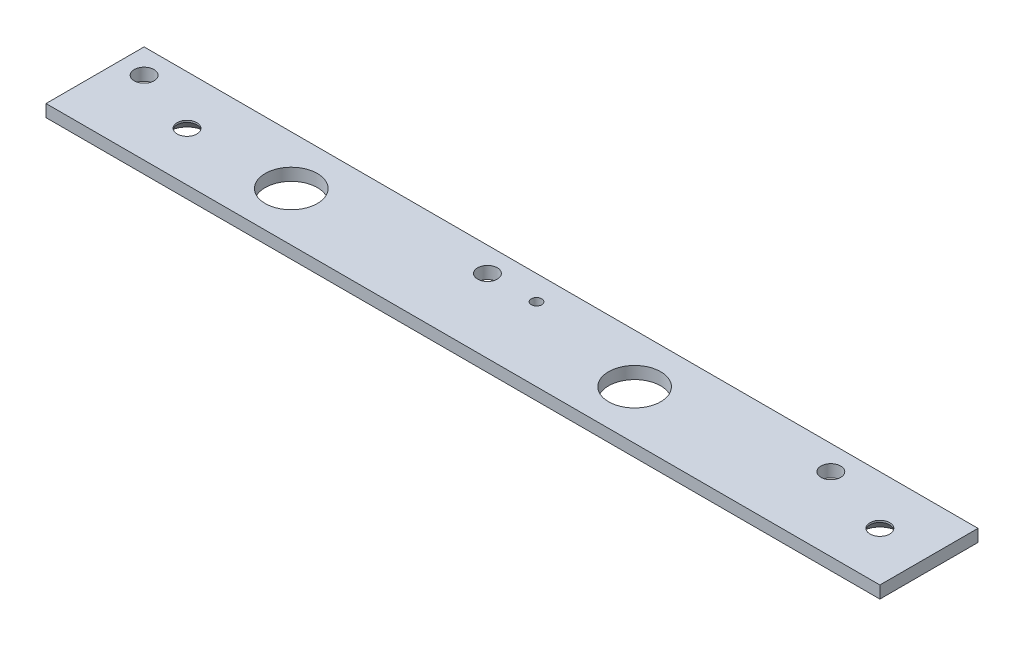
from build123d import *

# Parameters (mm, degrees)
SKETCH1_W                                    = 25.4
SKETCH1_H                                    = 3.175
BOSS_EXTRUDE1_DEPTH                          = 107.95
F_10_CLEARANCE_HOLE1_D                       = 5.1054
F_1_2_CLEARANCE_HOLE1_D                      = 13.49248
F_6_32_TAPPED_HOLE1_D                        = 2.7051
CSK_FOR_10_FLAT_HEAD_MACHINE_SCREW1_AT_COUNT = 2
CSK_FOR_10_FLAT_HEAD_MACHINE_SCREW1_AT_PITCH = 50.8
CSK_FOR_10_FLAT_HEAD_MACHINE_SCREW1_2_COUNT  = 2
CSK_FOR_10_FLAT_HEAD_MACHINE_SCREW1_2_PITCH  = 186.441720536
CSK_FOR_10_FLAT_HEAD_MACHINE_SCREW1_3_COUNT  = 2
CSK_FOR_10_FLAT_HEAD_MACHINE_SCREW1_3_PITCH  = 179.3875
CSK_FOR_10_FLAT_HEAD_MACHINE_SCREW1_4_COUNT  = 2
CSK_FOR_10_FLAT_HEAD_MACHINE_SCREW1_4_PITCH  = 331.7875
CSK_FOR_10_FLAT_HEAD_MACHINE_SCREW1_5_COUNT  = 2
CSK_FOR_10_FLAT_HEAD_MACHINE_SCREW1_5_PITCH  = 152.4
CSK_FOR_10_FLAT_HEAD_MACHINE_SCREW1_6_COUNT  = 2
CSK_FOR_10_FLAT_HEAD_MACHINE_SCREW1_6_PITCH  = 160.643705137
CSK_FOR_10_FLAT_HEAD_MACHINE_SCREW1_7_COUNT  = 2
CSK_FOR_10_FLAT_HEAD_MACHINE_SCREW1_7_PITCH  = 335.653966394


with BuildPart() as part:
    # Sketch1 → Boss-Extrude1 (new body, symmetric)
    with BuildSketch(Plane(origin=(0, 0, 0), x_dir=(0, 0, -1), z_dir=(1, 0, 0))):
        Rectangle(SKETCH1_W, SKETCH1_H)
    extrude(amount=BOSS_EXTRUDE1_DEPTH, both=True)

    # #10 Clearance Hole1 (through all)
    with Locations(Plane(origin=(0, 1.5875, 0), x_dir=(1, 0, 0), z_dir=(0, 1, 0))):
        with Locations((-101.6, 6.35), (-12.7, 6.35), (76.2, 6.35)):
            Hole(F_10_CLEARANCE_HOLE1_D / 2)

    # 1/2 Clearance Hole1 (through all)
    with Locations(Plane(origin=(0, 1.5875, 0), x_dir=(1, 0, 0), z_dir=(0, 1, 0))):
        with Locations((-57.15, 0), (31.75, 0)):
            Hole(F_1_2_CLEARANCE_HOLE1_D / 2)

    # #6-32 Tapped Hole1 (through all)
    with Locations(Plane(origin=(0, 1.5875, 0), x_dir=(1, 0, 0), z_dir=(0, 1, 0))):
        with Locations((0, 6.35)):
            Hole(F_6_32_TAPPED_HOLE1_D / 2)

    # Sketch9 → CSK for #10 Flat Head Machine Screw1 (revolve, cut)
    with BuildSketch(Plane(origin=(95.25, -1.5875, 50.8), x_dir=(0, 0, -1), z_dir=(1, 0, 0))):
        Polygon((0, 0), (0, 3.175), (2.5527, 3.175), (2.5527, 2.688180894), (4.8895, 0), align=None)
    csk_for_10_flat_head_machine_screw1 = revolve(axis=Axis((95.25, -7.9375, 50.8), (0, 1, 0)), mode=Mode.SUBTRACT)

    # CSK for #10 Flat Head Machine Screw1 at: CSK for #10 Flat Head Machine Screw1 ×2
    with Locations(*[(0, 0, -i * CSK_FOR_10_FLAT_HEAD_MACHINE_SCREW1_AT_PITCH) for i in range(1, CSK_FOR_10_FLAT_HEAD_MACHINE_SCREW1_AT_COUNT)]):
        add(csk_for_10_flat_head_machine_screw1, mode=Mode.SUBTRACT)

    # CSK for _10 Flat Head Machine Screw1 2: CSK for #10 Flat Head Machine Screw1 ×2
    with Locations(*[Vector(-0.962163938, 0, -0.272471204) * (i * CSK_FOR_10_FLAT_HEAD_MACHINE_SCREW1_2_PITCH) for i in range(1, CSK_FOR_10_FLAT_HEAD_MACHINE_SCREW1_2_COUNT)]):
        add(csk_for_10_flat_head_machine_screw1, mode=Mode.SUBTRACT)

    # CSK for _10 Flat Head Machine Screw1 3: CSK for #10 Flat Head Machine Screw1 ×2
    with Locations(*[(-i * CSK_FOR_10_FLAT_HEAD_MACHINE_SCREW1_3_PITCH, 0, 0) for i in range(1, CSK_FOR_10_FLAT_HEAD_MACHINE_SCREW1_3_COUNT)]):
        add(csk_for_10_flat_head_machine_screw1, mode=Mode.SUBTRACT)

    # CSK for _10 Flat Head Machine Screw1 4: CSK for #10 Flat Head Machine Screw1 ×2
    with Locations(*[(i * CSK_FOR_10_FLAT_HEAD_MACHINE_SCREW1_4_PITCH, 0, 0) for i in range(1, CSK_FOR_10_FLAT_HEAD_MACHINE_SCREW1_4_COUNT)]):
        add(csk_for_10_flat_head_machine_screw1, mode=Mode.SUBTRACT)

    # CSK for _10 Flat Head Machine Screw1 5: CSK for #10 Flat Head Machine Screw1 ×2
    with Locations(*[(i * CSK_FOR_10_FLAT_HEAD_MACHINE_SCREW1_5_PITCH, 0, 0) for i in range(1, CSK_FOR_10_FLAT_HEAD_MACHINE_SCREW1_5_COUNT)]):
        add(csk_for_10_flat_head_machine_screw1, mode=Mode.SUBTRACT)

    # CSK for _10 Flat Head Machine Screw1 6: CSK for #10 Flat Head Machine Screw1 ×2
    with Locations(*[Vector(0.948683298, 0, -0.316227766) * (i * CSK_FOR_10_FLAT_HEAD_MACHINE_SCREW1_6_PITCH) for i in range(1, CSK_FOR_10_FLAT_HEAD_MACHINE_SCREW1_6_COUNT)]):
        add(csk_for_10_flat_head_machine_screw1, mode=Mode.SUBTRACT)

    # CSK for _10 Flat Head Machine Screw1 7: CSK for #10 Flat Head Machine Screw1 ×2
    with Locations(*[Vector(0.988480796, 0, -0.151346342) * (i * CSK_FOR_10_FLAT_HEAD_MACHINE_SCREW1_7_PITCH) for i in range(1, CSK_FOR_10_FLAT_HEAD_MACHINE_SCREW1_7_COUNT)]):
        add(csk_for_10_flat_head_machine_screw1, mode=Mode.SUBTRACT)


solid = part.part
